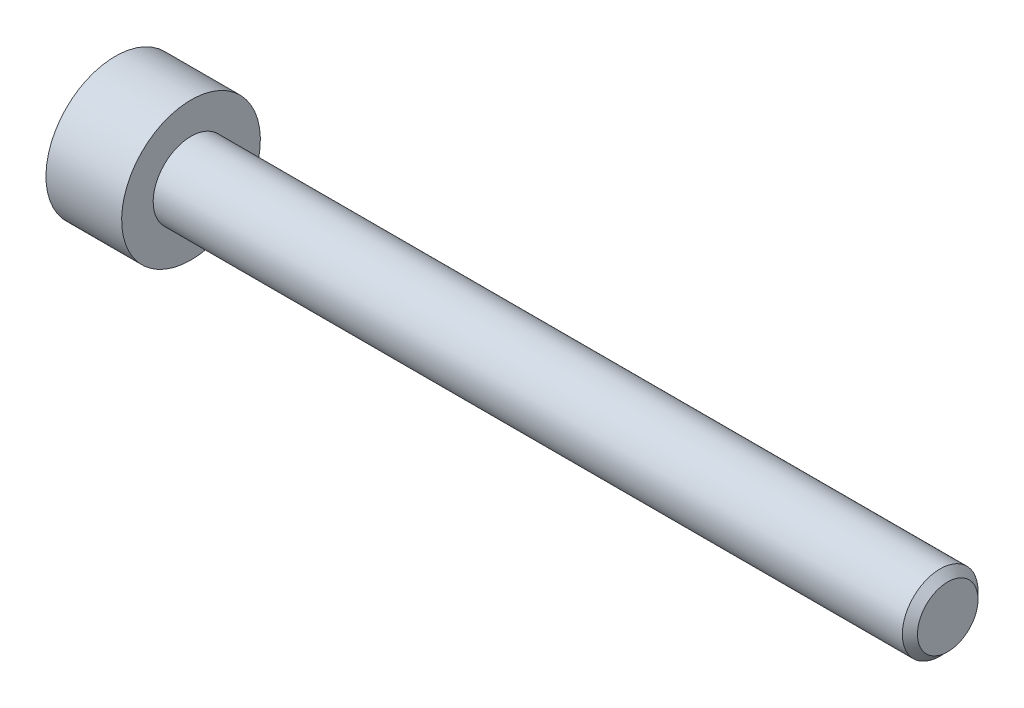
from build123d import *

# Parameters (mm, degrees)
SKETCH2_R           = 1.5
BOSS_EXTRUDE1_DEPTH = 30
CHAMFER1_SIZE       = 0.3
SKETCH6_W           = 3
SKETCH6_H           = 2.75
CUT_EXTRUDE1_DEPTH  = 1.6
SKETCH8_R           = 1.493375673
CUT_EXTRUDE2_DEPTH  = 1
CUT_EXTRUDE2_TAPER  = 45


with BuildPart() as part:
    # Sketch2 → Boss-Extrude1 (new body)
    with BuildSketch(Plane(origin=(0, 0, 0), x_dir=(0, 0, -1), z_dir=(1, 0, 0))):
        Circle(SKETCH2_R)
    extrude(amount=-BOSS_EXTRUDE1_DEPTH)

    # Chamfer1
    chamfer1_edges = [part.edges().sort_by_distance(p)[0] for p in [
        (0, 0, 1.5),
    ]]
    chamfer(chamfer1_edges, length=CHAMFER1_SIZE)

    # Sketch6 → Revolve1 (revolve)
    with BuildSketch(Plane.XY):
        with Locations((-31.5, 1.375)):
            Rectangle(SKETCH6_W, SKETCH6_H)
    revolve(axis=Axis((-30, 0, 0), (1, 0, 0)))

    # Sketch7 → Cut-Extrude1 (cut)
    with BuildSketch(Plane.ZY.offset(33)):
        Polygon((0, 1.443375673), (-1.25, 0.721687836), (-1.25, -0.721687836), (0, -1.443375673), (1.25, -0.721687836), (1.25, 0.721687836), align=None)
    extrude(amount=-CUT_EXTRUDE1_DEPTH, mode=Mode.SUBTRACT)

    # Sketch8 → Cut-Extrude2 (cut)
    with BuildSketch(Plane.ZY.offset(33)):
        Circle(SKETCH8_R)
    extrude(amount=-CUT_EXTRUDE2_DEPTH, taper=CUT_EXTRUDE2_TAPER, mode=Mode.SUBTRACT)


solid = part.part
